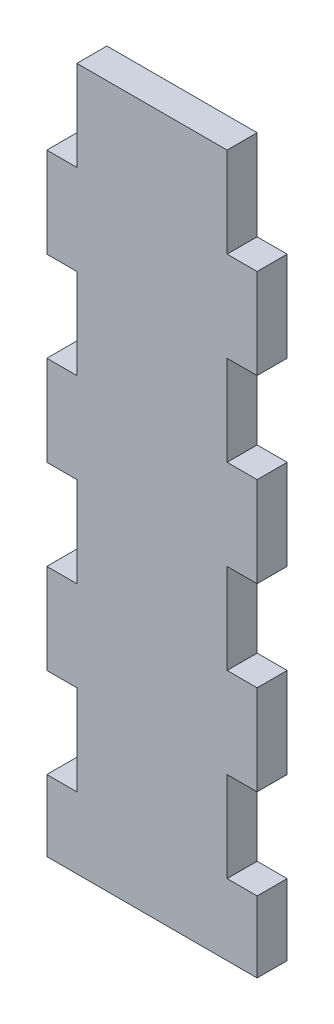
from build123d import *

# Parameters (mm, degrees)
BOSS_EXTRUDE1_DEPTH = 6


with BuildPart() as part:
    # Model → Boss-Extrude1 (new body)
    with BuildSketch(Plane.XY):
        Polygon((16.884090401, 128.021741477), (22.884090401, 128.021741477), (22.884090401, 146.021741477), (52.884090401, 146.021741477), (52.884090401, 128.021741477), (58.884090401, 128.021741477), (58.884090401, 110.021741477), (52.884090401, 110.021741477), (52.884090401, 92.021741477), (58.884090401, 92.021741477), (58.884090401, 74.021741477), (52.884090401, 74.021741477), (52.884090401, 56.021741477), (58.884090401, 56.021741477), (58.884090401, 38.021741477), (52.884090401, 38.021741477), (52.884090401, 20.021741477), (58.884090401, 20.021741477), (58.884090401, 5.829362613), (16.884090401, 5.829362613), (16.884090401, 20.021741477), (22.884090401, 20.021741477), (22.884090401, 38.021741477), (16.884090401, 38.021741477), (16.884090401, 56.021741477), (22.884090401, 56.021741477), (22.884090401, 74.021741477), (16.884090401, 74.021741477), (16.884090401, 92.021741477), (22.884090401, 92.021741477), (22.884090401, 110.021741477), (16.884090401, 110.021741477), align=None)
    extrude(amount=BOSS_EXTRUDE1_DEPTH)


solid = part.part
